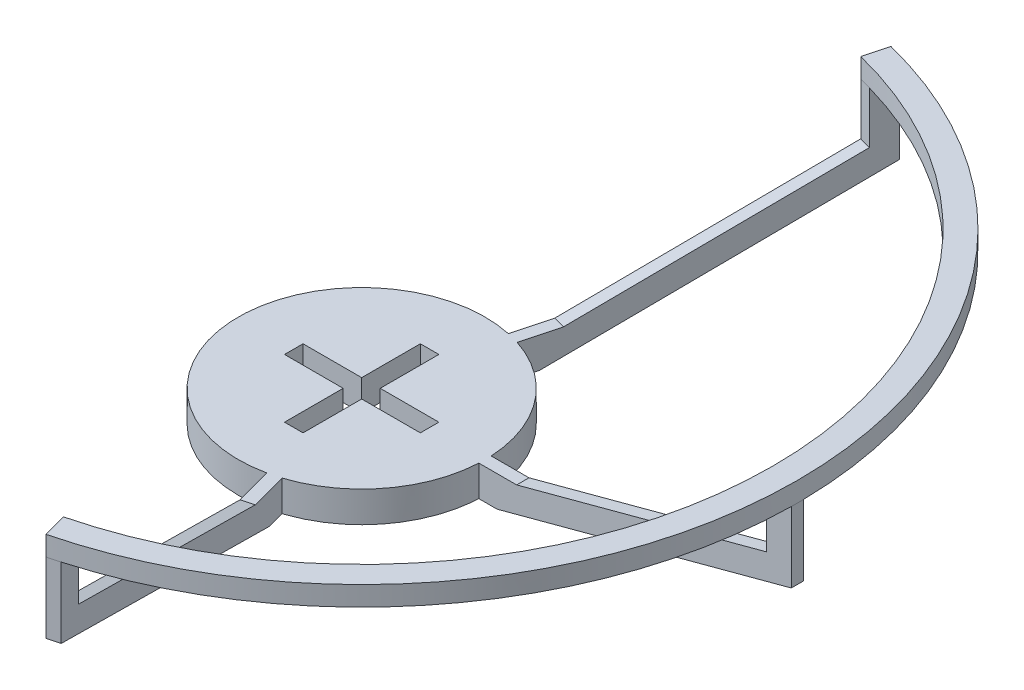
from build123d import *

# Parameters (mm, degrees)
SKETCH1_R           = 20
BOSS_EXTRUDE1_DEPTH = 5
BOSS_EXTRUDE2_DEPTH = 1
CIRPATTERN1_COUNT   = 2
CIRPATTERN1_ANGLE   = 75
CIRPATTERN3_COUNT   = 2
CIRPATTERN3_ANGLE   = 75
CUT_EXTRUDE1_REACH  = 102.171
BOSS_EXTRUDE3_DEPTH = 3.175


with BuildPart() as part:
    # Sketch1 → Boss-Extrude1 (new body)
    with BuildSketch(Plane(origin=(0, 0, 0), x_dir=(1, 0, 0), z_dir=(0, 1, 0))):
        Circle(SKETCH1_R)
    extrude(amount=BOSS_EXTRUDE1_DEPTH)

    # Sketch2 → Boss-Extrude2 (add, symmetric)
    with BuildSketch(Plane.XY):
        Polygon((19.75, 5), (26.1, 5), (66.58195138, 15.84710618), (66.58195138, 24.207798228), (70.58195138, 24.207798228), (70.58195138, 12.777798228), (22.917269596, 0.006085237), (19.75, 0.006085237), align=None)
    boss_extrude2 = extrude(amount=BOSS_EXTRUDE2_DEPTH, both=True)

    # CirPattern1: Boss-Extrude2 ×2 about axis
    cirpattern1_axis = Axis((0, 5, 0), (0, 1, 0))
    for i in range(1, CIRPATTERN1_COUNT):
        add(boss_extrude2.rotate(cirpattern1_axis, i * CIRPATTERN1_ANGLE / (CIRPATTERN1_COUNT - 1)))

    # CirPattern3: Boss-Extrude2 ×2 about axis
    cirpattern3_axis = Axis((0, 0, 0), (0, -1, 0))
    for i in range(1, CIRPATTERN3_COUNT):
        add(boss_extrude2.rotate(cirpattern3_axis, i * CIRPATTERN3_ANGLE / (CIRPATTERN3_COUNT - 1)))

    # Sketch5 → Cut-Extrude1 (cut, up to next)
    with BuildSketch(Plane(origin=(0, 5, 0), x_dir=(1, 0, 0), z_dir=(0, 1, 0)), mode=Mode.PRIVATE) as cut_extrude1_sk1:
        Polygon((-11, -1.5), (-1.5, -1.5), (-1.5, -11), (1.5, -11), (1.5, -1.5), (11, -1.5), (11, 1.5), (1.5, 1.5), (1.5, 11), (-1.5, 11), (-1.5, 1.5), (-11, 1.5), align=None)
    cut_extrude1_tool1 = extrude(cut_extrude1_sk1.sketch, amount=-CUT_EXTRUDE1_REACH, mode=Mode.PRIVATE) & part.part
    add(cut_extrude1_tool1.solids().sort_by_distance((0, 5, 0))[0], mode=Mode.SUBTRACT)

    # Sketch7 → Boss-Extrude3 (add)
    with BuildSketch(Plane(origin=(0, 24.207798228, 0), x_dir=(1, 0, 0), z_dir=(0, 1, 0))):
        with BuildLine():
            Line((17.302027431, 68.435748753), (16.266751251, 64.572045448))
            ThreePointArc((16.266751251, 64.572045448), (66.589460499, 0), (16.266751251, -64.572045448))
            Line((16.266751251, -64.572045448), (17.302027431, -68.435748753))
            ThreePointArc((17.302027431, -68.435748753), (70.589034988, 0), (17.302027431, 68.435748753))
        make_face()
    extrude(amount=BOSS_EXTRUDE3_DEPTH)


solid = part.part
